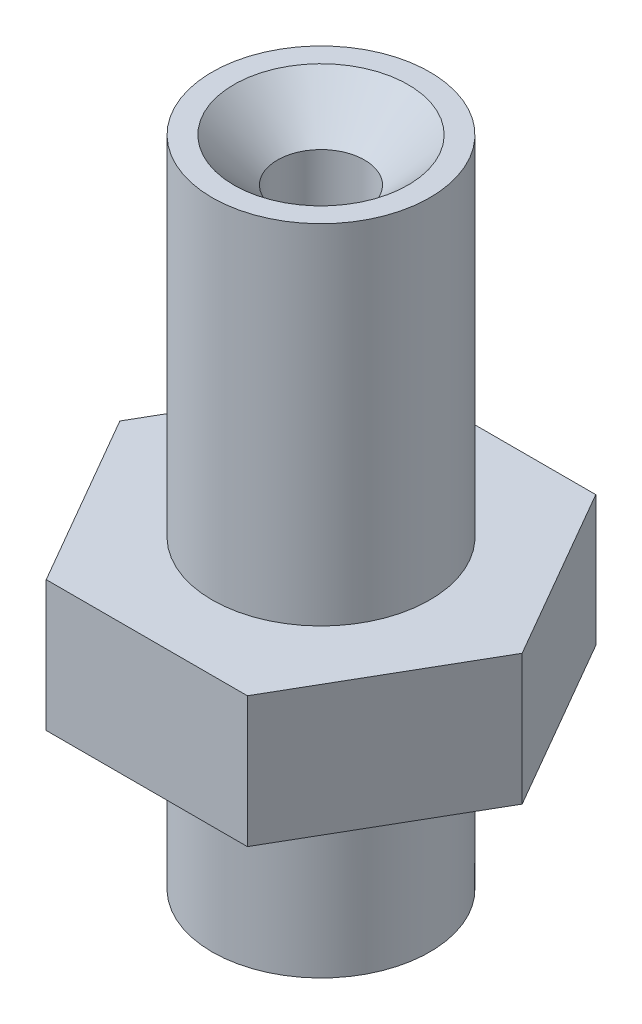
from build123d import *

# Parameters (mm, degrees)
BOSS_EXTRUDE1_DEPTH = 1.5
SKETCH4_R           = 2.5
BOSS_EXTRUDE3_DEPTH = 4
SKETCH2_R           = 2.5
BOSS_EXTRUDE2_DEPTH = 8
SKETCH3_R           = 1
CUT_EXTRUDE1_DEPTH  = 16
CHAMFER2_SIZE       = 1


with BuildPart() as part:
    # Sketch1 → Boss-Extrude1 (new body, symmetric)
    with BuildSketch(Plane(origin=(0, 0, 0), x_dir=(1, 0, 0), z_dir=(0, 1, 0))):
        Polygon((2.309401077, 4), (-2.309401077, 4), (-4.618802154, 0), (-2.309401077, -4), (2.309401077, -4), (4.618802154, 0), align=None)
    extrude(amount=BOSS_EXTRUDE1_DEPTH, both=True)

    # Sketch4 → Boss-Extrude3 (add)
    with BuildSketch(Plane.XZ.offset(1.5)):
        Circle(SKETCH4_R)
    extrude(amount=BOSS_EXTRUDE3_DEPTH)

    # Sketch2 → Boss-Extrude2 (add)
    with BuildSketch(Plane(origin=(0, 1.5, 0), x_dir=(1, 0, 0), z_dir=(0, 1, 0))):
        Circle(SKETCH2_R)
    extrude(amount=BOSS_EXTRUDE2_DEPTH)

    # Sketch3 → Cut-Extrude1 (cut, through all)
    with BuildSketch(Plane(origin=(0, 9.5, 0), x_dir=(1, 0, 0), z_dir=(0, 1, 0))):
        Circle(SKETCH3_R)
    extrude(amount=-CUT_EXTRUDE1_DEPTH, mode=Mode.SUBTRACT)

    # Chamfer2
    chamfer2_edges = [part.edges().sort_by_distance(p)[0] for p in [
        (-1, -5.5, 0),
        (-1, 9.5, 0),
    ]]
    chamfer(chamfer2_edges, length=CHAMFER2_SIZE)


solid = part.part
